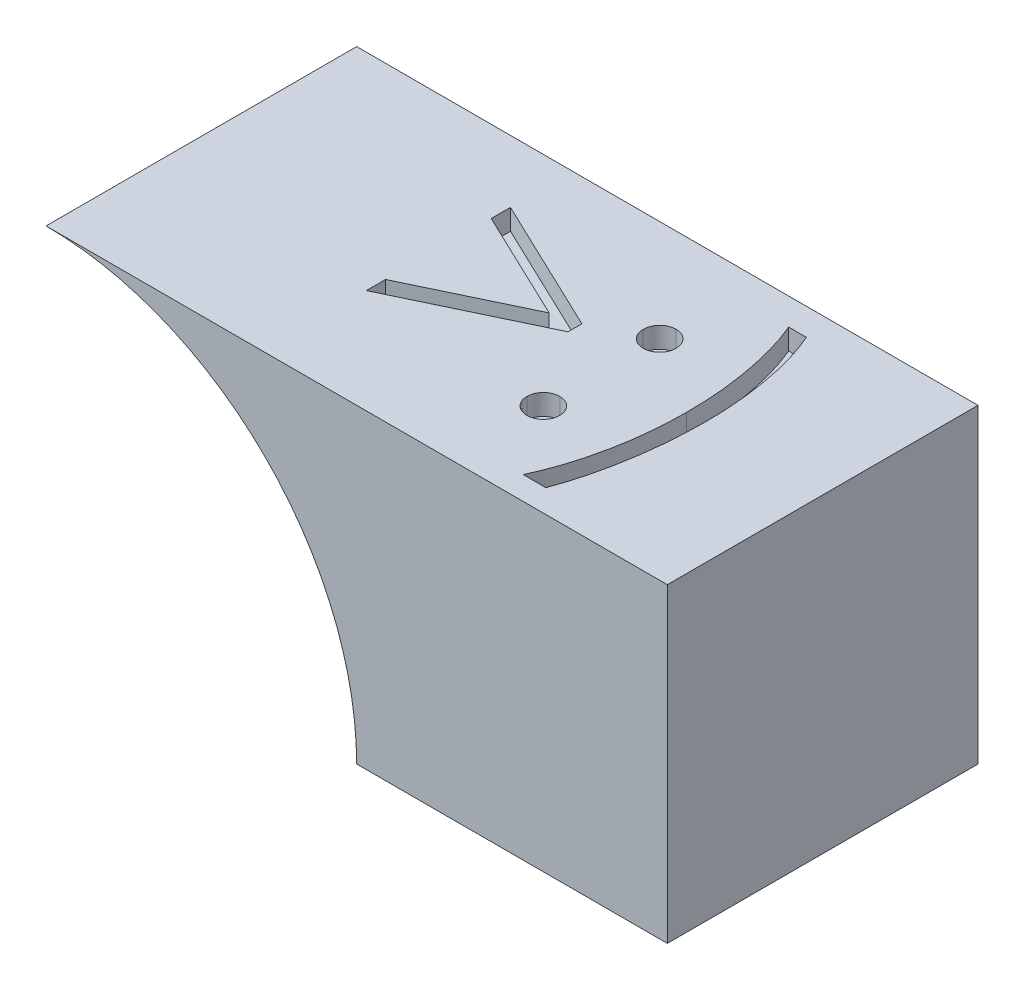
from build123d import *

# Parameters (mm, degrees)
SKETCH1_W           = 30
SKETCH1_H           = 15
BOSS_EXTRUDE1_DEPTH = 15
SKETCH2_R           = 15
CUT_EXTRUDE1_DEPTH  = 15
CUT_EXTRUDE2_DEPTH  = 1


with BuildPart() as part:
    # Sketch1 → Boss-Extrude1 (new body)
    with BuildSketch(Plane(origin=(0, 0, 0), x_dir=(1, 0, 0), z_dir=(0, 1, 0))):
        Rectangle(SKETCH1_W, SKETCH1_H)
    extrude(amount=BOSS_EXTRUDE1_DEPTH)

    # Sketch2 → Cut-Extrude1 (cut)
    with BuildSketch(Plane.XY.offset(7.5)):
        with Locations((-15, 0)):
            Circle(SKETCH2_R)
    extrude(amount=-CUT_EXTRUDE1_DEPTH, mode=Mode.SUBTRACT)

    # Sketch3 → Cut-Extrude2 (cut)
    with BuildSketch(Plane(origin=(0, 15, 0), x_dir=(1, 0, 0), z_dir=(0, 1, 0))):
        Polygon((-4.565210898, -1.540580661), (0.781153285, 1.010486046), (-4.565210898, 3.561552753), (-4.565210898, 4.490774507), (2.029019871, 1.344395301), (2.029019871, 0.676576791), (-4.565210898, -2.469802416), align=None)
        with BuildLine():
            add(Edge.make_bspline(
                [(4.532385256, 3.391736046), (4.585426476, 3.388584178), (4.689407588, 3.382405309), (4.83973693, 3.340014504), (4.975793825, 3.264743436), (5.096985148, 3.164424017), (5.196879202, 3.042787963), (5.274832761, 2.90781624), (5.316854299, 2.756228334), (5.322988159, 2.651644719), (5.326135256, 2.597986046)],
                knots=[0, 0, 0, 0, 0.000159102, 0.000311902, 0.000463876, 0.000622429, 0.000780981, 0.000933875, 0.001086674, 0.001247676, 0.001247676, 0.001247676, 0.001247676], degree=3))
            add(Edge.make_bspline(
                [(5.326135256, 2.597986046), (5.322988159, 2.544327373), (5.316854299, 2.439743758), (5.274832761, 2.288155852), (5.196879202, 2.153184129), (5.096985148, 2.031548075), (4.975793825, 1.931228656), (4.83973693, 1.855957587), (4.689407588, 1.813566782), (4.585426476, 1.807387914), (4.532385256, 1.804236046)],
                knots=[0, 0, 0, 0, 0.000161002, 0.000313801, 0.000466695, 0.000625248, 0.0007838, 0.000935775, 0.001088574, 0.001247676, 0.001247676, 0.001247676, 0.001247676], degree=3))
            add(Edge.make_bspline(
                [(4.532385256, 1.804236046), (4.479307324, 1.807283761), (4.375865992, 1.813223325), (4.226079814, 1.856876161), (4.089202284, 1.930531062), (3.968032593, 2.03173365), (3.867325054, 2.152555772), (3.792822649, 2.289085596), (3.747168888, 2.439306024), (3.741525683, 2.54423952), (3.738635256, 2.597986046)],
                knots=[0, 0, 0, 0, 0.000159102, 0.000310068, 0.000463722, 0.000622275, 0.000780827, 0.000932802, 0.001086136, 0.001247138, 0.001247138, 0.001247138, 0.001247138], degree=3))
            add(Edge.make_bspline(
                [(3.738635256, 2.597986046), (3.741631063, 2.650449237), (3.747548948, 2.754084477), (3.792844046, 2.903037506), (3.867230597, 3.039722332), (3.96867028, 3.160258542), (4.088470126, 3.2638968), (4.226513734, 3.336529736), (4.375479803, 3.383381479), (4.479237718, 3.388906159), (4.532385256, 3.391736046)],
                knots=[0, 0, 0, 0, 0.000157203, 0.000310538, 0.000462512, 0.000621065, 0.000780841, 0.000934495, 0.001086002, 0.001245105, 0.001245105, 0.001245105, 0.001245105], degree=3))
        make_face()
        with BuildLine():
            add(Edge.make_bspline(
                [(4.532385256, -2.225571646), (4.585426476, -2.228723514), (4.689407588, -2.234902383), (4.83973693, -2.277293188), (4.975793825, -2.352564257), (5.096985148, -2.452883675), (5.196879202, -2.57451973), (5.274832761, -2.709491453), (5.316854299, -2.861079358), (5.322988159, -2.965662974), (5.326135256, -3.019321646)],
                knots=[0, 0, 0, 0, 0.000159102, 0.000311902, 0.000463876, 0.000622429, 0.000780981, 0.000933875, 0.001086674, 0.001247676, 0.001247676, 0.001247676, 0.001247676], degree=3))
            add(Edge.make_bspline(
                [(5.326135256, -3.019321646), (5.322881514, -3.071690994), (5.316465182, -3.174962578), (5.274929085, -3.32540713), (5.196285105, -3.460463205), (5.09767416, -3.583749738), (4.975763866, -3.684281679), (4.839415269, -3.758912353), (4.689760488, -3.804338384), (4.585485351, -3.81012495), (4.532385256, -3.813071646)],
                knots=[0, 0, 0, 0, 0.000157203, 0.000310002, 0.000462897, 0.000622923, 0.000781475, 0.00093345, 0.001086785, 0.001245887, 0.001245887, 0.001245887, 0.001245887], degree=3))
            add(Edge.make_bspline(
                [(4.532385256, -3.813071646), (4.479246898, -3.810231571), (4.375506905, -3.804687001), (4.226410735, -3.757979649), (4.08923177, -3.684981518), (3.967345212, -3.583562286), (3.867908372, -3.46109761), (3.792727865, -3.324477007), (3.74757896, -3.175393238), (3.741641149, -3.071775817), (3.738635256, -3.019321646)],
                knots=[0, 0, 0, 0, 0.000159102, 0.000310609, 0.000464264, 0.000622816, 0.000782843, 0.000934817, 0.001088152, 0.001245355, 0.001245355, 0.001245355, 0.001245355], degree=3))
            add(Edge.make_bspline(
                [(3.738635256, -3.019321646), (3.741525683, -2.96557512), (3.747168888, -2.860641624), (3.792822649, -2.710421196), (3.867325054, -2.573891372), (3.968032593, -2.453069251), (4.089202284, -2.351866663), (4.226079814, -2.278211761), (4.375865992, -2.234558925), (4.479307324, -2.228619362), (4.532385256, -2.225571646)],
                knots=[0, 0, 0, 0, 0.000161002, 0.000314336, 0.000466311, 0.000624863, 0.000783415, 0.00093707, 0.001088035, 0.001247138, 0.001247138, 0.001247138, 0.001247138], degree=3))
        make_face()
        with BuildLine():
            Line((8.012673717, -6.377494723), (6.913635256, -6.377494723))
            add(Edge.make_bspline(
                [(6.913635256, -6.377494723), (6.964923037, -6.268556916), (7.068946293, -6.047606327), (7.207381282, -5.703499581), (7.344635711, -5.34898027), (7.470061478, -4.979429934), (7.587529774, -4.596798161), (7.699577806, -4.200923285), (7.798655827, -3.790991301), (7.927768443, -3.226973351), (8.061537871, -2.505405036), (8.172348909, -1.623616401), (8.244020266, -0.728938898), (8.252595321, -0.127485519), (8.256904487, 0.174758882)],
                knots=[0, 0, 0, 0, 0.000361147, 0.000732487, 0.001112362, 0.001501554, 0.001902903, 0.002313081, 0.002735593, 0.00316793, 0.004048889, 0.004935676, 0.005833185, 0.006739799, 0.006739799, 0.006739799, 0.006739799], degree=3))
            add(Edge.make_bspline(
                [(8.256904487, 0.174758882), (8.252902226, 0.454678656), (8.244972319, 1.009299641), (8.191798742, 1.834123368), (8.097085547, 2.6424037), (7.970871979, 3.430798715), (7.811358038, 4.187699516), (7.62592252, 4.903463701), (7.412126188, 5.57256258), (7.24119411, 5.994633525), (7.157866025, 6.200389892)],
                knots=[0, 0, 0, 0, 0.00083976, 0.001663864, 0.002478263, 0.003280358, 0.00405836, 0.004797909, 0.005497855, 0.006163637, 0.006163637, 0.006163637, 0.006163637], degree=3))
            Line((7.157866025, 6.200389892), (8.012673717, 6.200389892))
            add(Edge.make_bspline(
                [(8.012673717, 6.200389892), (8.054744003, 6.10338045), (8.139913324, 5.90698938), (8.256148684, 5.601782231), (8.365580554, 5.284503822), (8.472030365, 4.95493584), (8.568429545, 4.612298427), (8.65782742, 4.256424857), (8.742333903, 3.88830928), (8.843284081, 3.378212649), (8.953267541, 2.726122679), (9.043476277, 1.92739898), (9.100527601, 1.113721058), (9.107966351, 0.565368415), (9.111712179, 0.289242056)],
                knots=[0, 0, 0, 0, 0.000317185, 0.000642126, 0.000979441, 0.001323997, 0.001680966, 0.002047019, 0.002424721, 0.002813889, 0.003606878, 0.00440779, 0.005224405, 0.00605272, 0.00605272, 0.00605272, 0.00605272], degree=3))
            add(Edge.make_bspline(
                [(9.111712179, 0.289242056), (9.108657505, -0.008500857), (9.10258886, -0.600019428), (9.046302547, -1.482164848), (8.960344753, -2.353183983), (8.835781357, -3.209818768), (8.680204435, -4.045048948), (8.494446198, -4.852986274), (8.274075254, -5.629424741), (8.099072178, -6.130242561), (8.012673717, -6.377494723)],
                knots=[0, 0, 0, 0, 0.000893134, 0.001774367, 0.002650754, 0.003518288, 0.004370411, 0.005198895, 0.006004563, 0.006790171, 0.006790171, 0.006790171, 0.006790171], degree=3))
        make_face()
    extrude(amount=-CUT_EXTRUDE2_DEPTH, mode=Mode.SUBTRACT)


solid = part.part
